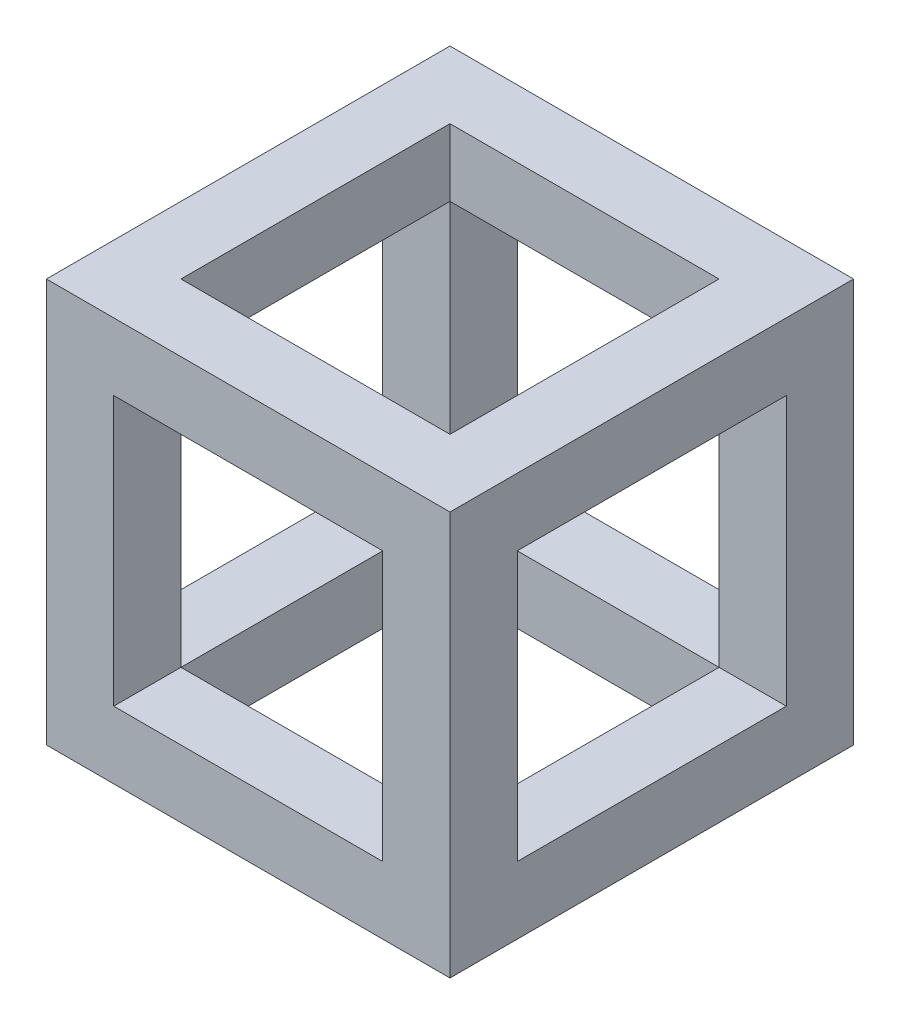
from build123d import *

# Parameters (mm, degrees)
ESQUISSE1_W             = 30
ESQUISSE1_H             = 30
BOSS_EXTRU_1_DEPTH      = 30
ESQUISSE2_W             = 20
ESQUISSE2_H             = 20
ENL_V_MAT_EXTRU_1_DEPTH = 31
ESQUISSE3_W             = 20
ESQUISSE3_H             = 20
ENL_V_MAT_EXTRU_2_DEPTH = 31
ESQUISSE4_W             = 20
ESQUISSE4_H             = 20
ENL_V_MAT_EXTRU_3_DEPTH = 31


with BuildPart() as part:
    # Esquisse1 → Boss.-Extru.1 (new body)
    with BuildSketch(Plane.XY):
        with Locations((15, 15)):
            Rectangle(ESQUISSE1_W, ESQUISSE1_H)
    extrude(amount=BOSS_EXTRU_1_DEPTH)

    # Esquisse2 → Enlèv. mat.-Extru.1 (cut, through all)
    with BuildSketch(Plane(origin=(0, 30, 0), x_dir=(1, 0, 0), z_dir=(0, 1, 0))):
        with Locations((15, -15)):
            Rectangle(ESQUISSE2_W, ESQUISSE2_H)
    extrude(amount=-ENL_V_MAT_EXTRU_1_DEPTH, mode=Mode.SUBTRACT)

    # Esquisse3 → Enlèv. mat.-Extru.2 (cut, through all)
    with BuildSketch(Plane.XY.offset(30)):
        with Locations((15, 15)):
            Rectangle(ESQUISSE3_W, ESQUISSE3_H)
    extrude(amount=-ENL_V_MAT_EXTRU_2_DEPTH, mode=Mode.SUBTRACT)

    # Esquisse4 → Enlèv. mat.-Extru.3 (cut, through all)
    with BuildSketch(Plane(origin=(30, 0, 0), x_dir=(0, 0, -1), z_dir=(1, 0, 0))):
        with Locations((-15, 15)):
            Rectangle(ESQUISSE4_W, ESQUISSE4_H)
    extrude(amount=-ENL_V_MAT_EXTRU_3_DEPTH, mode=Mode.SUBTRACT)


solid = part.part
